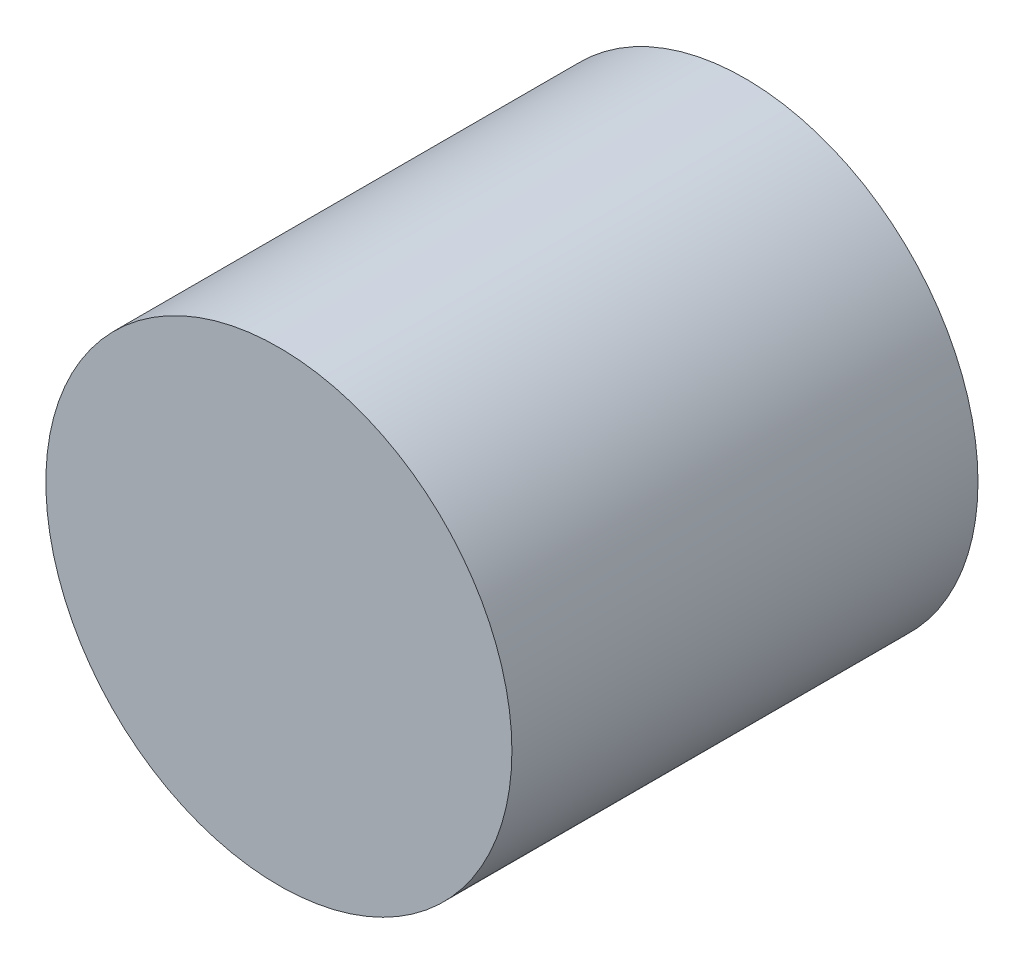
from build123d import *

# Parameters (mm, degrees)
SZKIC1_R                    = 5
DODANIE_WYCI_GNI_CIE1_DEPTH = 10


with BuildPart() as part:
    # Szkic1 → Dodanie-wyciągnięcie1 (new body)
    with BuildSketch(Plane.XY):
        Circle(SZKIC1_R)
    extrude(amount=DODANIE_WYCI_GNI_CIE1_DEPTH)


solid = part.part
